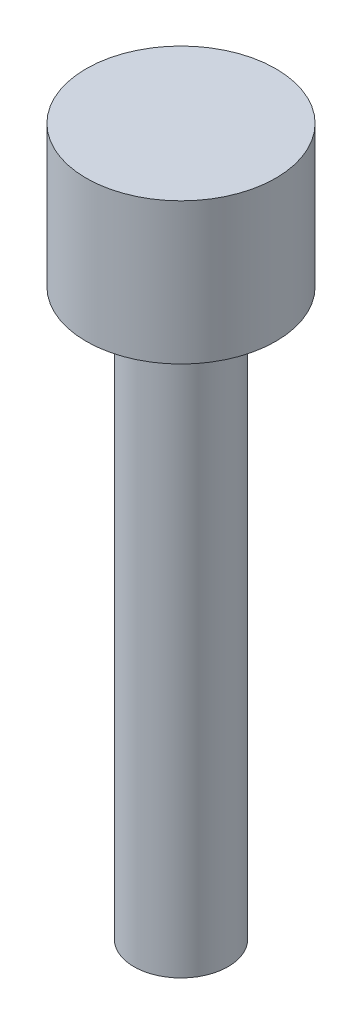
from build123d import *


with BuildPart() as part:
    # Sketch1 → Revolve1 (revolve)
    with BuildSketch(Plane.XY):
        Polygon((0, 0), (0, 15), (2.012585073, 15), (2.012585073, 12), (1, 12), (1, 0), align=None)
    revolve(axis=Axis((0, 0, 0), (0, 1, 0)))


solid = part.part
